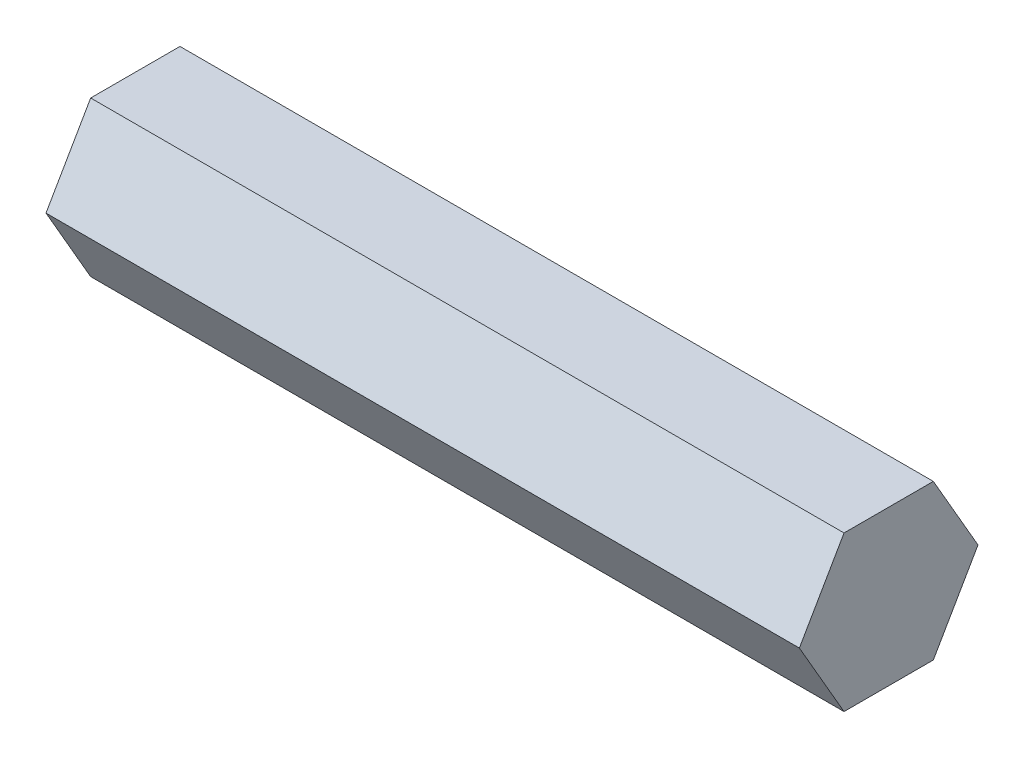
from build123d import *

# Parameters (mm, degrees)
BOSS_EXTRUDE1_DEPTH = 61.85


with BuildPart() as part:
    # Sketch1 → Boss-Extrude1 (new body)
    with BuildSketch(Plane(origin=(0, 0, 0), x_dir=(0, 0, -1), z_dir=(1, 0, 0))):
        Polygon((7.332348419, 0), (3.666174209, 6.35), (-3.666174209, 6.35), (-7.332348419, 0), (-3.666174209, -6.35), (3.666174209, -6.35), align=None)
    extrude(amount=BOSS_EXTRUDE1_DEPTH)


solid = part.part
